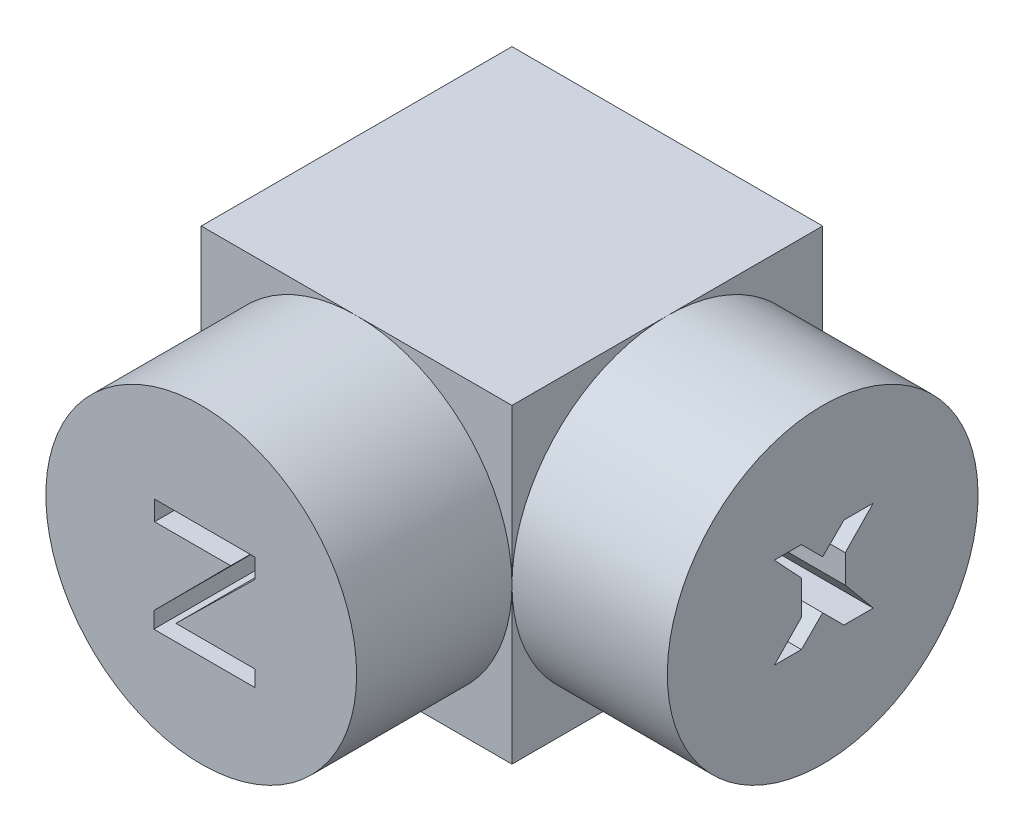
from build123d import *

# Parameters (mm, degrees)
EXTRUDE1_DEPTH      = 0.025
EXTRUDE1_DEPTH_BACK = 0.025
SKETCH1_W           = 0.05
SKETCH1_H           = 0.05
SKETCH3_R           = 0.025004715
EXTRUDE2_DEPTH      = 0.025
SKETCH4_R           = 0.025
EXTRUDE3_DEPTH      = 0.025


with BuildPart() as part:
    # Sketch1 → Extrude1 (new, two sides: drawn at the far end of the back side and taken through both)
    with BuildSketch(Plane.XY.offset(-EXTRUDE1_DEPTH_BACK)):
        Rectangle(SKETCH1_W, SKETCH1_H)
    extrude(amount=EXTRUDE1_DEPTH + EXTRUDE1_DEPTH_BACK)

    # Sketch3 → Extrude2 (add)
    with BuildSketch(Plane.XY.offset(0.025)):
        Circle(SKETCH3_R)
        Polygon((-0.007509787, 0.008189552), (0.008610359, 0.008189552), (0.008610359, 0.005025204), (-0.004078591, -0.007412678), (0.008610359, -0.007412678), (0.008610359, -0.01000226), (-0.007639266, -0.01000226), (-0.007639266, -0.007412678), (0.004725987, 0.005025204), (-0.007509787, 0.005025204), align=None, mode=Mode.SUBTRACT)
    extrude(amount=EXTRUDE2_DEPTH)

    # Sketch4 → Extrude3 (add)
    with BuildSketch(Plane(origin=(0.025, 0, 0), x_dir=(0, 0, -1), z_dir=(1, 0, 0))):
        Circle(SKETCH4_R)
        Polygon((-0.007772542, 0.007316304), (-0.003420279, 0.007316304), (0, 0.003896025), (0.003420279, 0.007316304), (0.00813573, 0.007316304), (0.003633389, 0.002663885), (0.003633389, -0.001871079), (0.00813573, -0.007316304), (0.003420279, -0.007316304), (0, -0.003896025), (-0.003420279, -0.007316304), (-0.007772542, -0.007316304), (-0.003420279, -0.002818966), (-0.003420279, 0.002663885), align=None, mode=Mode.SUBTRACT)
    extrude(amount=EXTRUDE3_DEPTH)


solid = part.part
